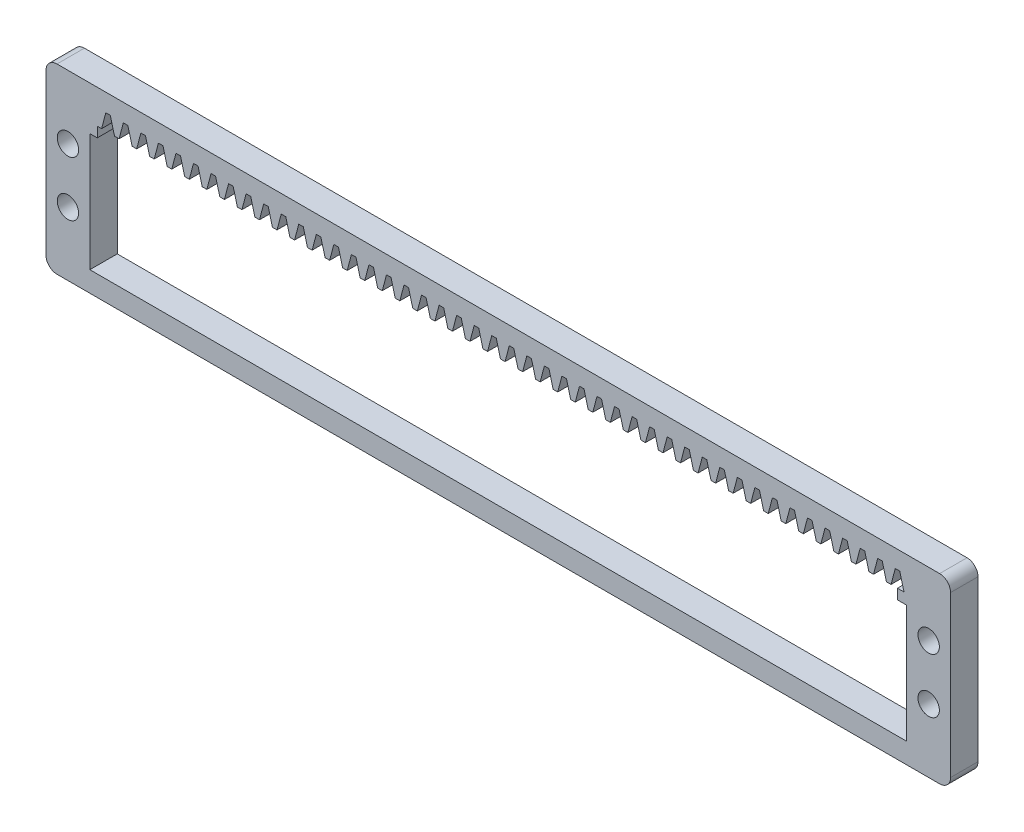
from build123d import *

# Parameters (mm, degrees)
BOSS_EXTRUDE1_DEPTH = 5
SKETCH2_W           = 149
SKETCH2_H           = 21.5
CUT_EXTRUDE1_DEPTH  = 6
SKETCH3_W           = 145.97
SKETCH3_H           = 1.85
CUT_EXTRUDE2_DEPTH  = 6
CUT_EXTRUDE4_DEPTH  = 6
LPATTERN1_COUNT     = 46
LPATTERN1_PITCH     = 3.2
SKETCH5_R           = 1.95
CUT_EXTRUDE5_DEPTH  = 10


with BuildPart() as part:
    # Sketch1 → Boss-Extrude1 (new body)
    with BuildSketch(Plane.XY):
        with BuildLine():
            Line((2, 0), (163, 0))
            ThreePointArc((163, 0), (164.414213562, -0.585786438), (165, -2))
            Line((165, -2), (165, -31.22))
            ThreePointArc((165, -31.22), (164.414213562, -32.634213562), (163, -33.22))
            Line((163, -33.22), (2, -33.22))
            ThreePointArc((2, -33.22), (0.585786438, -32.634213562), (0, -31.22))
            Line((0, -31.22), (0, -2))
            ThreePointArc((0, -2), (0.585786438, -0.585786438), (2, 0))
        make_face()
    extrude(amount=BOSS_EXTRUDE1_DEPTH)

    # Sketch2 → Cut-Extrude1 (cut, through all)
    with BuildSketch(Plane.XY.offset(5)):
        with Locations((82.5, -18.75)):
            Rectangle(SKETCH2_W, SKETCH2_H)
    extrude(amount=-CUT_EXTRUDE1_DEPTH, mode=Mode.SUBTRACT)

    # Sketch3 → Cut-Extrude2 (cut, through all)
    with BuildSketch(Plane.XY.offset(5)):
        with Locations((82.335, -7.075)):
            Rectangle(SKETCH3_W, SKETCH3_H)
    extrude(amount=-CUT_EXTRUDE2_DEPTH, mode=Mode.SUBTRACT)

    # Sketch4 → Cut-Extrude4 (cut, through all)
    with BuildSketch(Plane.XY.offset(5)):
        Polygon((155.735, -3.249176841), (156.5, -6.15), (154.14, -6.15), (154.905, -3.249176841), align=None)
    cut_extrude4 = extrude(amount=-CUT_EXTRUDE4_DEPTH, mode=Mode.SUBTRACT)

    # LPattern1: Cut-Extrude4 ×46
    with Locations(*[(-i * LPATTERN1_PITCH, 0, 0) for i in range(1, LPATTERN1_COUNT)]):
        add(cut_extrude4, mode=Mode.SUBTRACT)

    # Sketch5 → Cut-Extrude5 (cut)
    with BuildSketch(Plane.XY.offset(5)):
        with Locations((4, -11.61)):
            Circle(SKETCH5_R)
        with Locations((4, -21.61)):
            Circle(SKETCH5_R)
        with Locations((161, -11.61)):
            Circle(SKETCH5_R)
        with Locations((161, -21.61)):
            Circle(SKETCH5_R)
    extrude(amount=-CUT_EXTRUDE5_DEPTH, mode=Mode.SUBTRACT)


solid = part.part
